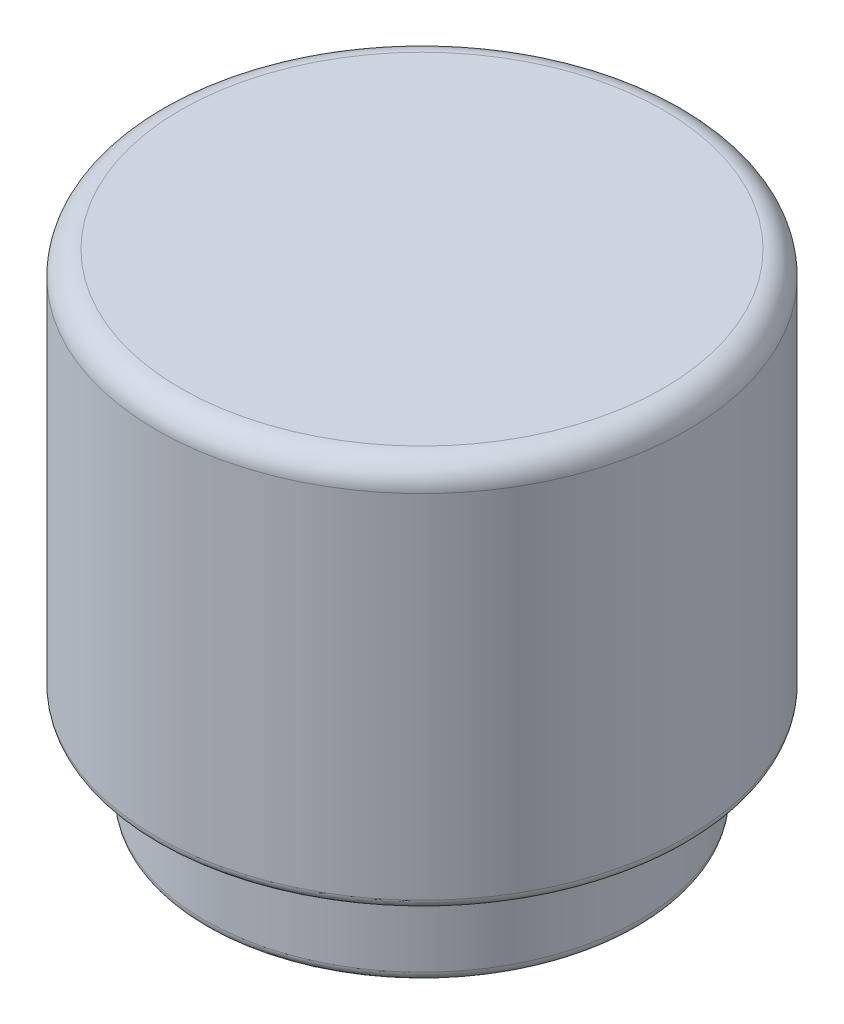
from build123d import *

# Parameters (mm, degrees)
FILLET1_R = 0.5
FILLET2_R = 0.2


with BuildPart() as part:
    # Sketch1 → Revolve1 (revolve)
    with BuildSketch(Plane(origin=(0, 0, 0), x_dir=(0, 0, -1), z_dir=(1, 0, 0))):
        Polygon((0, 0), (-5.5, 0), (-5.5, -8), (-4.5, -8), (-4.5, -10), (-4, -10), (-4, -7.5), (-5, -7.5), (-5, -0.5), (0, -0.5), align=None)
    revolve(axis=Axis((0, 0, 0), (0, -1, 0)))

    # Fillet1
    fillet1_edges = [part.edges().sort_by_distance(p)[0] for p in [
        (0, 0, -5.5),
    ]]
    fillet(fillet1_edges, radius=FILLET1_R)

    # Fillet2
    fillet2_edges = [part.edges().sort_by_distance(p)[0] for p in [
        (0, -0.5, -5),
        (0, -8, -5.5),
        (0, -10, -4.5),
        (0, -10, -4),
        (0, -7.5, -4),
    ]]
    fillet(fillet2_edges, radius=FILLET2_R)


solid = part.part
